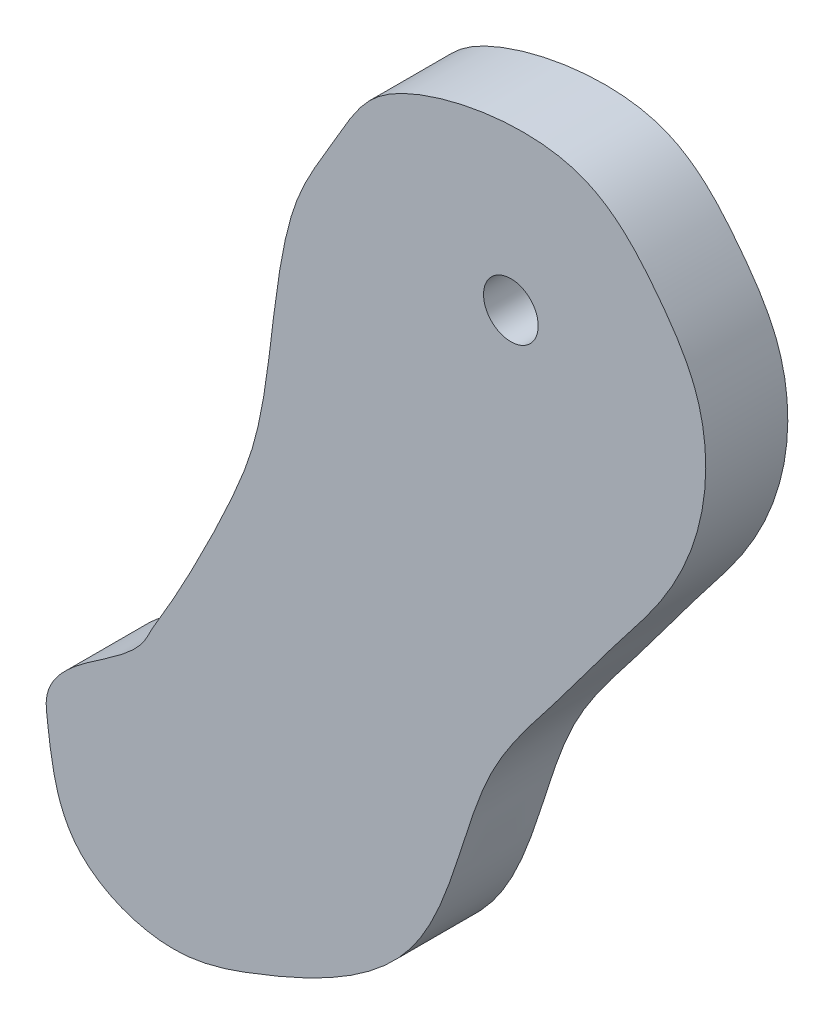
from build123d import *

# Parameters (mm, degrees)
SKETCH1_R           = 1
BOSS_EXTRUDE1_DEPTH = 3
SKETCH2_R           = 1
BOSS_EXTRUDE2_DEPTH = 3


with BuildPart() as part:
    # Sketch1 → Boss-Extrude1 (new body)
    with BuildSketch(Plane.XY):
        with BuildLine():
            add(Edge.make_bspline(
                [(-13.918757964, -4.983277033), (-13.891383954, -3.856108575), (-10.519528688, -1.847207627), (-10.15952415, -0.739910558), (-9.272984168, 0.450357546), (-6.604605959, 5.868720596), (-5.864340997, 8.435277808), (-5.26305396, 14.99373349), (-2.888138482, 18.830239706), (-1.956057525, 21.071387992), (5.392926098, 22.626862951), (8.270108814, 19.44454224), (10.188758933, 16.628829382), (10.346098917, 13.012388386), (8.936984393, 9.788698355), (6.753445037, 7.130727515), (4.748993926, 4.311308471), (2.045919629, 1.084536496), (1.136018218, -2.793840299), (-0.883041283, -7.339605048), (-5.113265684, -9.390724794), (-9.482726866, -10.885261605), (-13.415080666, -9.347761886), (-13.754952706, -6.54607838), (-13.922105439, -5.121114674), (-13.918757964, -4.983277033)],
                knots=[0, 0, 0, 0, 0.03889202, 0.095791071, 0.170637325, 0.206387983, 0.248875395, 0.278358672, 0.297921346, 0.348786262, 0.419462087, 0.462880557, 0.494962177, 0.536060756, 0.581869625, 0.614364109, 0.655354427, 0.702626506, 0.758040335, 0.792049077, 0.871887561, 0.908934811, 0.952440256, 0.995244026, 1, 1, 1, 1], degree=3))
        make_face()
        with Locations((3.071435422, 15.942572669)):
            Circle(SKETCH1_R, mode=Mode.SUBTRACT)
    extrude(amount=BOSS_EXTRUDE1_DEPTH)

    # Sketch2 → Boss-Extrude2 (add)
    with BuildSketch(Plane(origin=(0, 0, 0), x_dir=(-1, 0, 0), z_dir=(0, 0, -1))):
        with Locations((10.302545155, -6.510167076)):
            Circle(SKETCH2_R)
    extrude(amount=BOSS_EXTRUDE2_DEPTH)


solid = part.part
